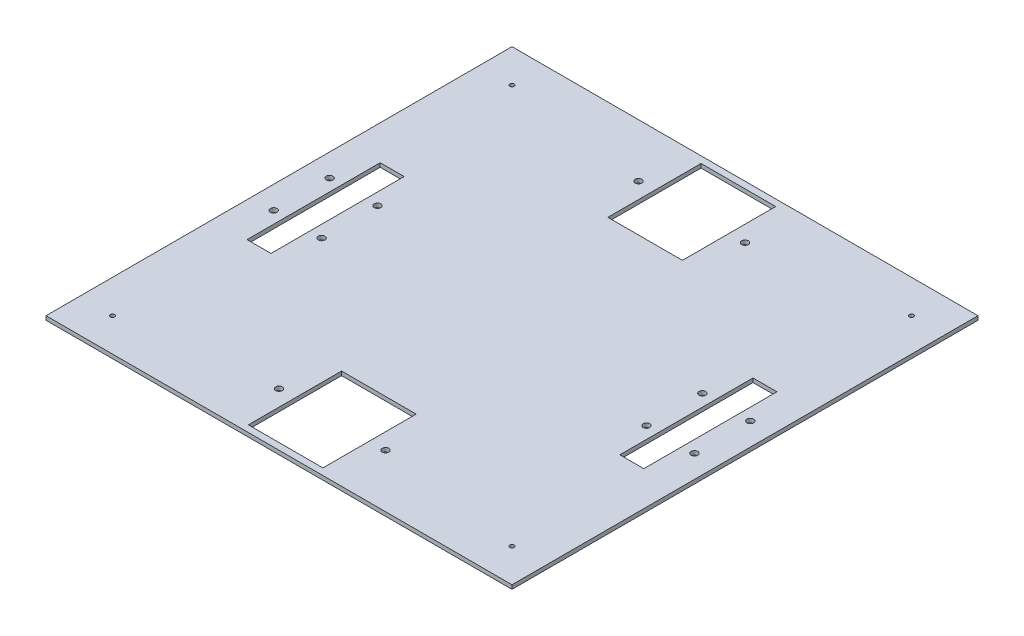
from build123d import *

# Parameters (mm, degrees)
SKETCH1_W           = 350
SKETCH1_H           = 350
BOSS_EXTRUDE1_DEPTH = 3
SKETCH3_W           = 18
SKETCH3_H           = 100
CUT_EXTRUDE1_DEPTH  = 3
SKETCH4_W           = 56
SKETCH4_H           = 70
CUT_EXTRUDE2_DEPTH  = 3
SKETCH5_R           = 2.5
SKETCH5_R_2         = 1.6
CUT_EXTRUDE3_DEPTH  = 3


with BuildPart() as part:
    # Sketch1 → Boss-Extrude1 (new body)
    with BuildSketch(Plane(origin=(0, 0, 0), x_dir=(1, 0, 0), z_dir=(0, 1, 0))):
        Rectangle(SKETCH1_W, SKETCH1_H)
    extrude(amount=BOSS_EXTRUDE1_DEPTH)

    # Sketch3 → Cut-Extrude1 (cut)
    with BuildSketch(Plane(origin=(0, 3, 0), x_dir=(1, 0, 0), z_dir=(0, 1, 0))):
        with Locations((-140, 0)):
            Rectangle(SKETCH3_W, SKETCH3_H)
        with Locations((140, 0)):
            Rectangle(SKETCH3_W, SKETCH3_H)
    extrude(amount=-CUT_EXTRUDE1_DEPTH, mode=Mode.SUBTRACT)

    # Sketch4 → Cut-Extrude2 (cut)
    with BuildSketch(Plane(origin=(0, 3, 0), x_dir=(1, 0, 0), z_dir=(0, 1, 0))):
        with Locations((0, 135.000000303)):
            Rectangle(SKETCH4_W, SKETCH4_H)
        with Locations((0, -135.000003084)):
            Rectangle(SKETCH4_W, SKETCH4_H)
    extrude(amount=-CUT_EXTRUDE2_DEPTH, mode=Mode.SUBTRACT)

    # Sketch5 → Cut-Extrude3 (cut)
    with BuildSketch(Plane(origin=(0, 3, 0), x_dir=(1, 0, 0), z_dir=(0, 1, 0))):
        with Locations((-158, 21)):
            Circle(SKETCH5_R)
        with Locations((-158, -21)):
            Circle(SKETCH5_R)
        with Locations((-122, 21)):
            Circle(SKETCH5_R)
        with Locations((-122, -21)):
            Circle(SKETCH5_R)
        with Locations((158, 21)):
            Circle(SKETCH5_R)
        with Locations((158, -21)):
            Circle(SKETCH5_R)
        with Locations((122, 21)):
            Circle(SKETCH5_R)
        with Locations((122, -21)):
            Circle(SKETCH5_R)
        with Locations((-39.999996759, -135.000003084)):
            Circle(SKETCH5_R)
        with Locations((39.999996759, -135.000003084)):
            Circle(SKETCH5_R)
        with Locations((-39.999996759, 135.000000303)):
            Circle(SKETCH5_R)
        with Locations((39.999996759, 135.000000303)):
            Circle(SKETCH5_R)
        with Locations((-150, 150)):
            Circle(SKETCH5_R_2)
        with Locations((150, 150)):
            Circle(SKETCH5_R_2)
        with Locations((150, -150)):
            Circle(SKETCH5_R_2)
        with Locations((-150, -150)):
            Circle(SKETCH5_R_2)
    extrude(amount=-CUT_EXTRUDE3_DEPTH, mode=Mode.SUBTRACT)


solid = part.part
